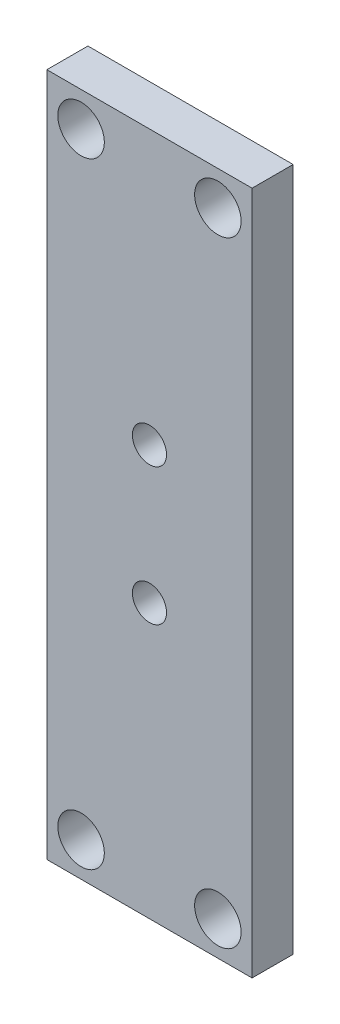
from build123d import *

# Parameters (mm, degrees)
SKETCH_1_W             = 15
SKETCH_1_H             = 50
EXTRUDE_1_DEPTH        = 3
HOLE_WIZARD_M3_1_D     = 2.5
HOLE_WIZARD_M3_1_DEPTH = 3
HOLE_WIZARD_M3_1_2_D   = 3.4


with BuildPart() as part:
    # 스케치1 → 보스-돌출1 (new body)
    with BuildSketch(Plane.XY):
        Rectangle(SKETCH_1_W, SKETCH_1_H)
    extrude(amount=EXTRUDE_1_DEPTH)

    # Hole Wizard M3 _ _1
    with Locations(Plane.XY.offset(3)):
        with Locations((0, 5), (0, -5)):
            Hole(HOLE_WIZARD_M3_1_D / 2, depth=HOLE_WIZARD_M3_1_DEPTH)

    # Hole Wizard M3 _ _1 2 (through all)
    with Locations(Plane.XY.offset(3)):
        with Locations((-5, 22.5), (5, 22.5), (-5, -22.5), (5, -22.5)):
            Hole(HOLE_WIZARD_M3_1_2_D / 2)


solid = part.part
